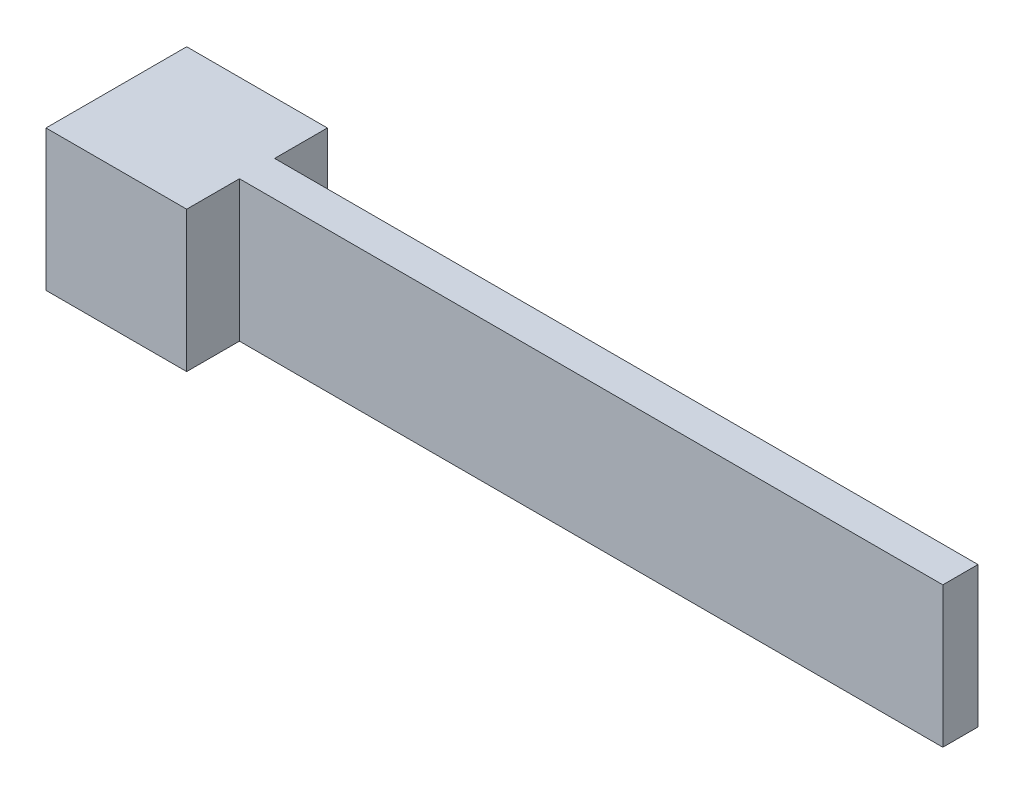
from build123d import *

# Parameters (mm, degrees)
SKETCH1_W           = 6
SKETCH1_H           = 6
BOSS_EXTRUDE1_DEPTH = 6
SKETCH2_W           = 1.5
SKETCH2_H           = 6
BOSS_EXTRUDE2_DEPTH = 30
SKETCH3_R           = 1.5
CUT_EXTRUDE1_DEPTH  = 5


with BuildPart() as part:
    # Sketch1 → Boss-Extrude1 (new body)
    with BuildSketch(Plane(origin=(0, 0, 0), x_dir=(0, 0, -1), z_dir=(1, 0, 0))):
        Rectangle(SKETCH1_W, SKETCH1_H)
    extrude(amount=BOSS_EXTRUDE1_DEPTH)

    # Sketch2 → Boss-Extrude2 (add)
    with BuildSketch(Plane(origin=(6, 0, 0), x_dir=(0, 0, -1), z_dir=(1, 0, 0))):
        Rectangle(SKETCH2_W, SKETCH2_H)
    extrude(amount=BOSS_EXTRUDE2_DEPTH)

    # Sketch3 → Cut-Extrude1 (cut)
    with BuildSketch(Plane.ZY):
        Circle(SKETCH3_R)
    extrude(amount=-CUT_EXTRUDE1_DEPTH, mode=Mode.SUBTRACT)


solid = part.part
